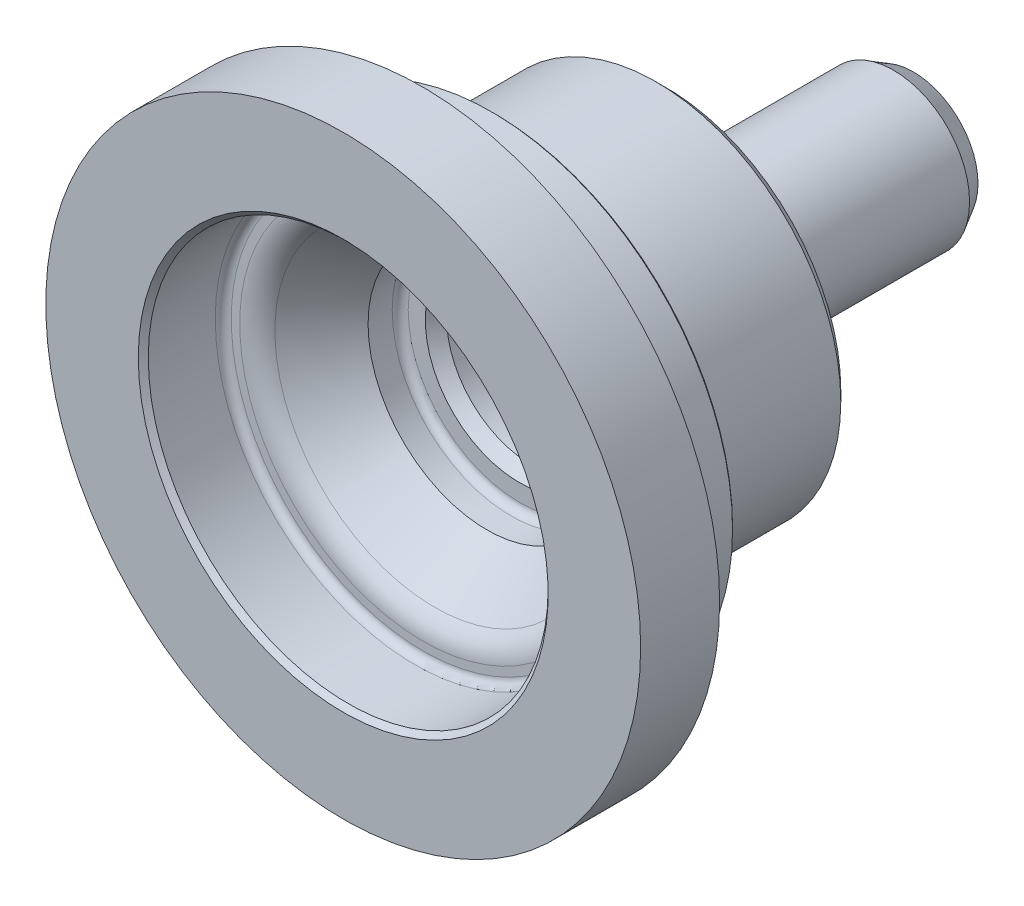
from build123d import *

# Parameters (mm, degrees)
FASE1_SIZE                                           = 1
FASE2_SIZE                                           = 0.22
FASE3_SIZE                                           = 0.5
FORMSENKUNG_F_R_M3_LINSENSENKSCHRAUBE_MI_D           = 3.4
FORMSENKUNG_F_R_M3_LINSENSENKSCHRAUBE_MI_DEPTH       = 6.5
FORMSENKUNG_F_R_M3_LINSENSENKSCHRAUBE_MI_CSINK_D     = 6.7
FORMSENKUNG_F_R_M3_LINSENSENKSCHRAUBE_MI_CSINK_ANGLE = 90
FORMSENKUNG_F_R_M3_LINSENSENKSCHRAUBE_MI_TIP         = 1.021463052


with BuildPart() as part:
    # Skizze1 → Rotation1 (revolve)
    with BuildSketch(Plane(origin=(0, 0, 0), x_dir=(0, 0, -1), z_dir=(1, 0, 0)), mode=Mode.PRIVATE) as rotation1_sk:
        with BuildLine():
            Line((57.5, 0), (57.5, 5.8))
            Line((57.5, 5.8), (57.046905424, 6.447086116))
            Line((57.046905424, 6.447086116), (55.05, 7.6))
            Line((55.05, 7.6), (36.706236111, 7.6))
            ThreePointArc((36.706236111, 7.6), (33.753828653, 7.679133577), (32.3, 10.25))
            Line((32.3, 10.25), (32.3, 18.47))
            Line((32.3, 18.47), (18.85, 18.47))
            Line((18.85, 18.47), (17.083308176, 17.45))
            Line((17.083308176, 17.45), (16.07, 17.45))
            ThreePointArc((16.07, 17.45), (15.348751083, 17.748751083), (15.05, 18.47))
            Line((15.05, 18.47), (15.05, 24.1125))
            Line((15.05, 24.1125), (7.9, 24.1125))
            Line((7.9, 24.1125), (7.15, 24.1125))
            ThreePointArc((7.15, 24.1125), (6.630384758, 24.4125), (6.630384758, 25.0125))
            Line((6.630384758, 25.0125), (7.9, 27.211538106))
            Line((7.9, 27.211538106), (7.9, 29.75))
            Line((7.9, 29.75), (0, 29.75))
            Line((0, 29.75), (0, 20))
            Line((0, 20), (7.2, 20))
            ThreePointArc((7.2, 20), (7.765685425, 19.765685425), (8, 19.2))
            Line((8, 19.2), (8, 18.351082532))
            ThreePointArc((8, 18.351082532), (8.303617861, 17.035969092), (9.153015574, 15.987050271))
            Line((9.153015574, 15.987050271), (14.384201369, 11.9))
            Line((14.384201369, 11.9), (16.8, 11.9))
            ThreePointArc((16.8, 11.9), (17.365685425, 11.665685425), (17.6, 11.1))
            Line((17.6, 11.1), (17.6, 9.387542752))
            Line((17.6, 9.387542752), (18.8, 8.45))
            Line((18.8, 8.45), (26.5, 8.45))
            ThreePointArc((26.5, 8.45), (27.065685425, 8.215685425), (27.3, 7.65))
            Line((27.3, 7.65), (27.3, 5.5))
            Line((27.3, 5.5), (31.3, 5.5))
            Line((31.3, 5.5), (31.3, 0))
            Line((31.3, 0), (57.5, 0))
        make_face()
    revolve(rotation1_sk.sketch.rotate(Axis((0, 0, 0), (0, 0, -1)), 90), axis=Axis((0, 0, 0), (0, 0, -1)))  # turned: the seam where the file's is

    # Fase1
    fase1_edges = [part.edges().sort_by_distance(p)[0] for p in [
        (-18.47, 0, -32.3),
    ]]
    chamfer(fase1_edges, length=FASE1_SIZE)

    # Fase2
    fase2_edges = [part.edges().sort_by_distance(p)[0] for p in [
        (-24.1125, 0, -15.05),
    ]]
    chamfer(fase2_edges, length=FASE2_SIZE)

    # Fase3
    fase3_edges = [part.edges().sort_by_distance(p)[0] for p in [
        (-20, 0, 0),
    ]]
    chamfer(fase3_edges, length=FASE3_SIZE)

    # Formsenkung für M3 Linsensenkschraube mit Schlitz3
    with Locations(Plane(origin=(0, 0, -57.5), x_dir=(-1, 0, 0), z_dir=(0, 0, -1))):
        with Locations((0, 0)):
            CounterSinkHole(FORMSENKUNG_F_R_M3_LINSENSENKSCHRAUBE_MI_D / 2, FORMSENKUNG_F_R_M3_LINSENSENKSCHRAUBE_MI_CSINK_D / 2, depth=FORMSENKUNG_F_R_M3_LINSENSENKSCHRAUBE_MI_DEPTH, counter_sink_angle=FORMSENKUNG_F_R_M3_LINSENSENKSCHRAUBE_MI_CSINK_ANGLE)
            with Locations((0, 0, -(FORMSENKUNG_F_R_M3_LINSENSENKSCHRAUBE_MI_DEPTH + FORMSENKUNG_F_R_M3_LINSENSENKSCHRAUBE_MI_TIP / 2))):  # 118° drill point
                Cone(0, FORMSENKUNG_F_R_M3_LINSENSENKSCHRAUBE_MI_D / 2, FORMSENKUNG_F_R_M3_LINSENSENKSCHRAUBE_MI_TIP, mode=Mode.SUBTRACT)


solid = part.part
